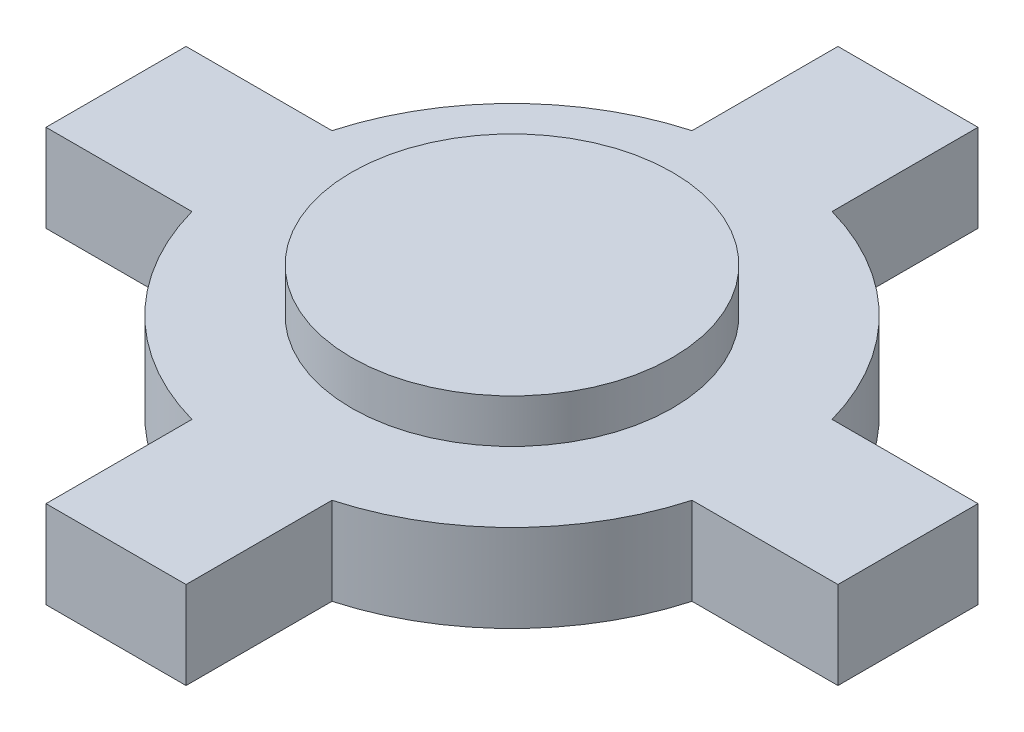
from build123d import *

# Parameters (mm, degrees)
EXTRUDE_1_DEPTH = 3
SKETCH_2_R      = 5.5
EXTRUDE_2_DEPTH = 1.5


with BuildPart() as part:
    # 草图1 → 凸台-拉伸1 (new body)
    with BuildSketch(Plane(origin=(0, 0, 0), x_dir=(1, 0, 0), z_dir=(0, 1, 0))):
        with BuildLine():
            Line((-13.570297544, 2.4), (-8.570297544, 2.4))
            ThreePointArc((-8.570297544, 2.4), (-6.293250353, 6.293250353), (-2.4, 8.570297544))
            Line((-2.4, 8.570297544), (-2.4, 13.570297544))
            Line((-2.4, 13.570297544), (2.4, 13.570297544))
            Line((2.4, 13.570297544), (2.4, 8.570297544))
            ThreePointArc((2.4, 8.570297544), (6.293250353, 6.293250353), (8.570297544, 2.4))
            Line((8.570297544, 2.4), (13.570297544, 2.4))
            Line((13.570297544, 2.4), (13.570297544, -2.4))
            Line((13.570297544, -2.4), (8.570297544, -2.4))
            ThreePointArc((8.570297544, -2.4), (6.293250353, -6.293250353), (2.4, -8.570297544))
            Line((2.4, -8.570297544), (2.4, -13.570297544))
            Line((2.4, -13.570297544), (-2.4, -13.570297544))
            Line((-2.4, -13.570297544), (-2.4, -8.570297544))
            ThreePointArc((-2.4, -8.570297544), (-6.293250353, -6.293250353), (-8.570297544, -2.4))
            Line((-8.570297544, -2.4), (-13.570297544, -2.4))
            Line((-13.570297544, -2.4), (-13.570297544, 2.4))
        make_face()
    extrude(amount=EXTRUDE_1_DEPTH)

    # 草图2 → 凸台-拉伸2 (add)
    with BuildSketch(Plane(origin=(0, 3, 0), x_dir=(1, 0, 0), z_dir=(0, 1, 0))):
        Circle(SKETCH_2_R)
    extrude(amount=EXTRUDE_2_DEPTH)


solid = part.part
